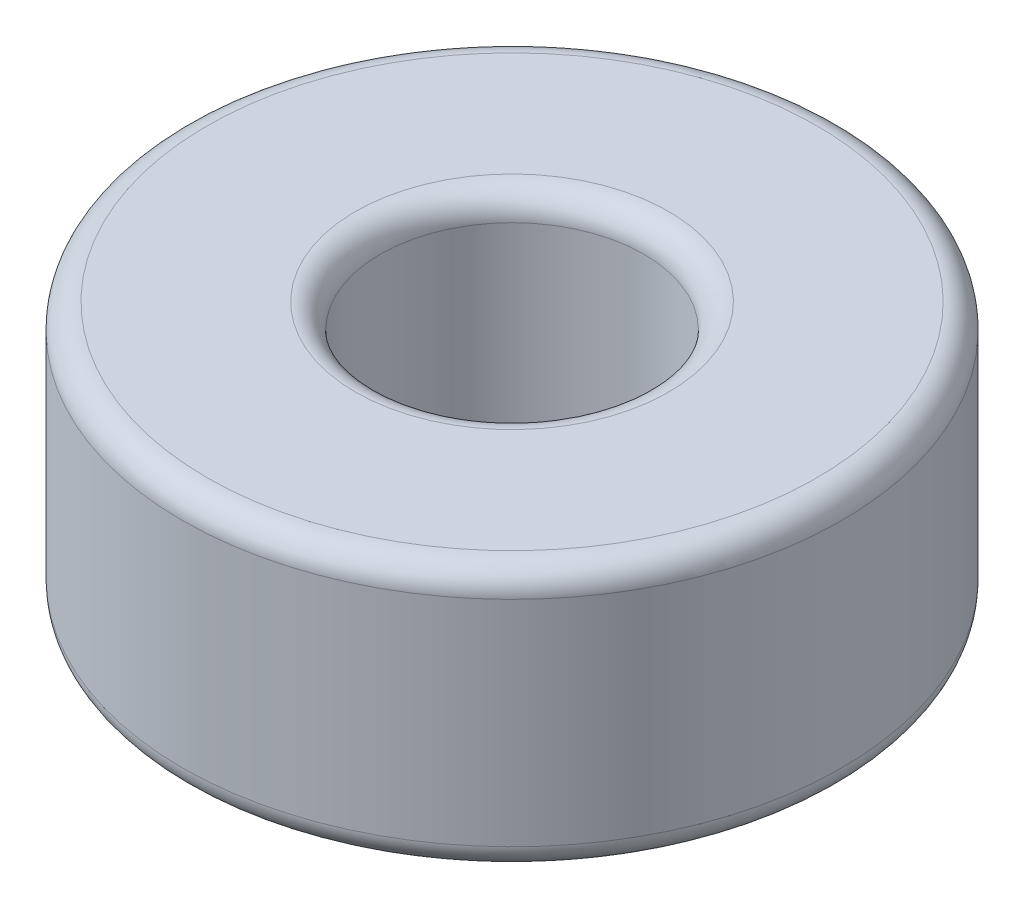
from build123d import *

# Parameters (mm, degrees)
SKETCH1_R               = 5
BOSS_EXTRUDE1_DEPTH     = 2
SKETCH2_R               = 2
CUT_EXTRUDE1_DEPTH      = 3
CUT_EXTRUDE1_DEPTH_BACK = 3
FILLET1_R               = 0.375


with BuildPart() as part:
    # Sketch1 → Boss-Extrude1 (new body, symmetric)
    with BuildSketch(Plane(origin=(0, 0, 0), x_dir=(1, 0, 0), z_dir=(0, 1, 0))):
        Circle(SKETCH1_R)
    extrude(amount=BOSS_EXTRUDE1_DEPTH, both=True)

    # Sketch2 → Cut-Extrude1 (cut, two sides)
    with BuildSketch(Plane(origin=(0, 0, 0), x_dir=(1, 0, 0), z_dir=(0, 1, 0))) as cut_extrude1_sk:
        Circle(SKETCH2_R)
    extrude(amount=CUT_EXTRUDE1_DEPTH, mode=Mode.SUBTRACT)
    extrude(cut_extrude1_sk.sketch, amount=-CUT_EXTRUDE1_DEPTH_BACK, mode=Mode.SUBTRACT)

    # Fillet1
    fillet1_edges = [part.edges().sort_by_distance(p)[0] for p in [
        (-5, -2, 0),
        (-5, 2, 0),
        (-2, -2, 0),
        (-2, 2, 0),
    ]]
    fillet(fillet1_edges, radius=FILLET1_R)


solid = part.part
